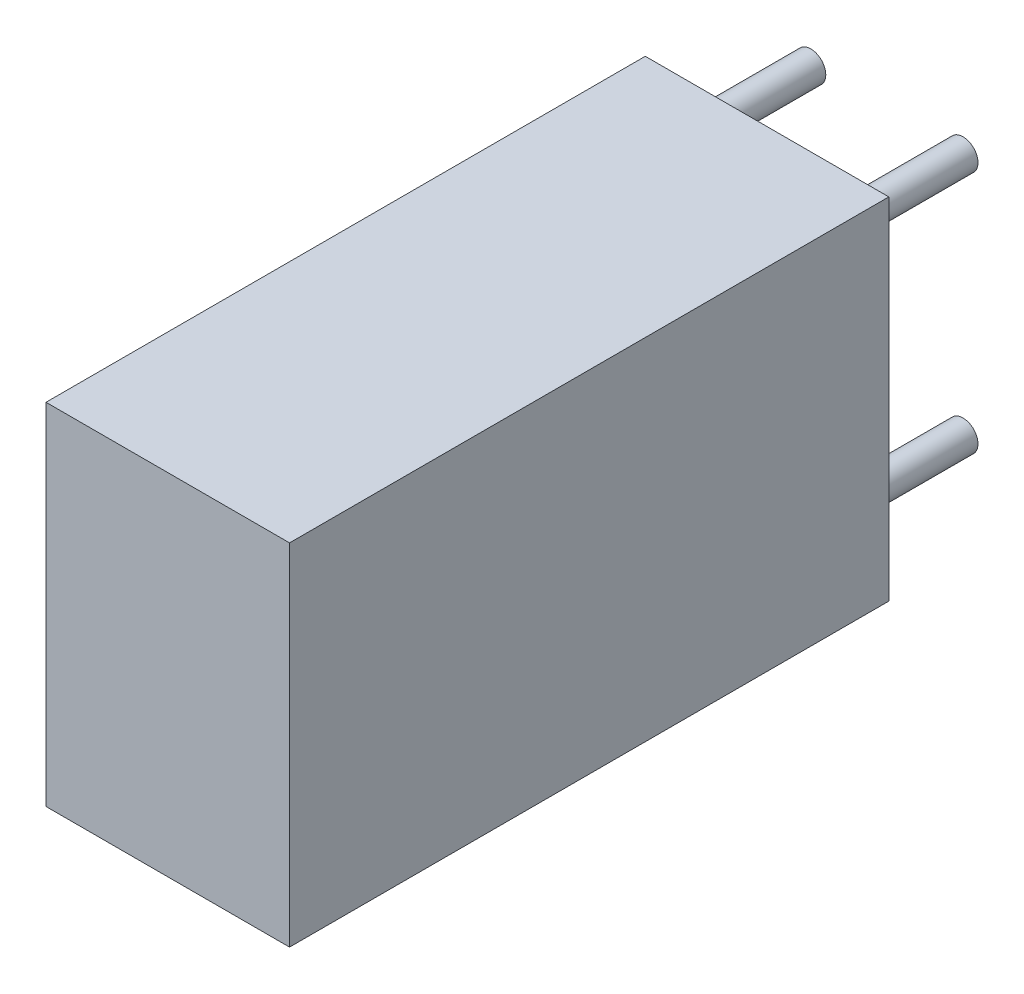
from build123d import *

# Parameters (mm, degrees)
SKETCH1_W               = 4.064
SKETCH1_H               = 5.842
COMPONENT_OUTLINE_DEPTH = 10
SKETCH2_R               = 0.25
EXTRUDE_1_DEPTH         = 2
SKETCH3_R               = 0.25
EXTRUDE_2_DEPTH         = 2
SKETCH4_R               = 0.25
EXTRUDE_3_DEPTH         = 2
SKETCH5_R               = 0.25
EXTRUDE_4_DEPTH         = 2


with BuildPart() as part:
    # Sketch1 → Component_Outline (new body)
    with BuildSketch(Plane.XY):
        with Locations((1.27, 1.905)):
            Rectangle(SKETCH1_W, SKETCH1_H)
    extrude(amount=COMPONENT_OUTLINE_DEPTH)


with BuildPart() as body_2:
    # Sketch2 → Extrude 1 (new body)
    with BuildSketch(Plane.XY):
        with Locations((0, 4.064)):
            Circle(SKETCH2_R)
    extrude(amount=-EXTRUDE_1_DEPTH)


with BuildPart() as body_3:
    # Sketch3 → Extrude 2 (new body)
    with BuildSketch(Plane.XY):
        with Locations((2.54, 4.064)):
            Circle(SKETCH3_R)
    extrude(amount=-EXTRUDE_2_DEPTH)


with BuildPart() as body_4:
    # Sketch4 → Extrude 3 (new body)
    with BuildSketch(Plane.XY):
        with Locations((2.54, 0)):
            Circle(SKETCH4_R)
    extrude(amount=-EXTRUDE_3_DEPTH)


with BuildPart() as body_5:
    # Sketch5 → Extrude 4 (new body)
    with BuildSketch(Plane.XY):
        Circle(SKETCH5_R)
    extrude(amount=-EXTRUDE_4_DEPTH)


solid = Compound([part.part, body_2.part, body_3.part, body_4.part, body_5.part])
